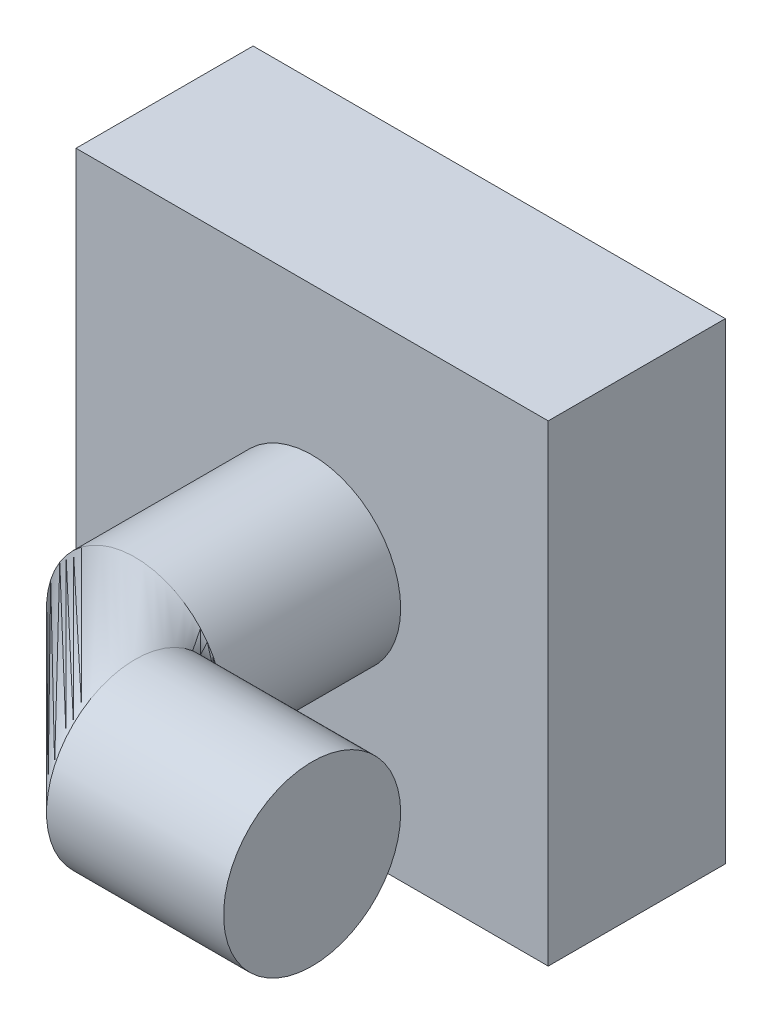
from build123d import *

# Parameters (mm, degrees)
SKETCH2_R           = 19.05
SKETCH3_W           = 101.6
SKETCH3_H           = 101.6
BOSS_EXTRUDE1_DEPTH = 38.1


with BuildPart() as part:
    # Sweep1: sweep along a path in Sketch1
    with BuildLine(Plane(origin=(0, 0, 0), x_dir=(1, 0, 0), z_dir=(0, 1, 0))) as sweep1_path:
        Line((57.15, 0), (19.05, 0))
        ThreePointArc((19.05, 0), (5.579615818, 5.579615818), (0, 19.05))
        Line((0, 19.05), (0, 57.15))
    # Sketch2 → Sweep1 (sweep)
    with BuildSketch(Plane(origin=(57.15, 0, 0), x_dir=(0, 0, -1), z_dir=(1, 0, 0))):
        Circle(SKETCH2_R)
    sweep(path=sweep1_path.line)

    # Sketch3 → Boss-Extrude1 (add)
    with BuildSketch(Plane(origin=(0, 0, -57.15), x_dir=(-1, 0, 0), z_dir=(0, 0, -1))):
        Rectangle(SKETCH3_W, SKETCH3_H)
    extrude(amount=BOSS_EXTRUDE1_DEPTH)


solid = part.part
